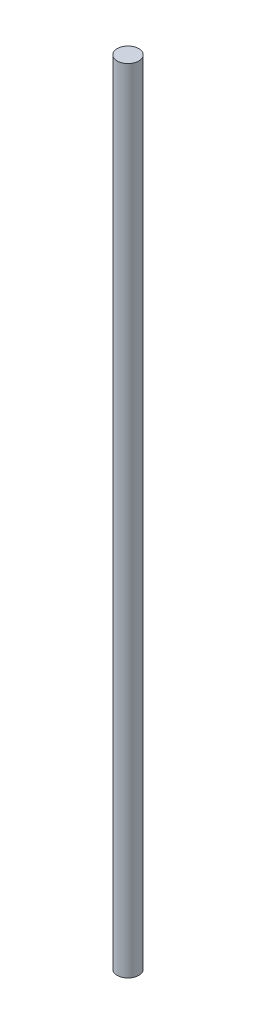
from build123d import *

# Parameters (mm, degrees)
SKETCH2_W = 4.7625
SKETCH2_H = 350


with BuildPart() as part:
    # Sketch2 → Revolve1 (revolve)
    with BuildSketch(Plane.XY):
        with Locations((-2.38125, 175)):
            Rectangle(SKETCH2_W, SKETCH2_H)
    revolve(axis=Axis((0, 0, 0), (0, 1, 0)))


solid = part.part
